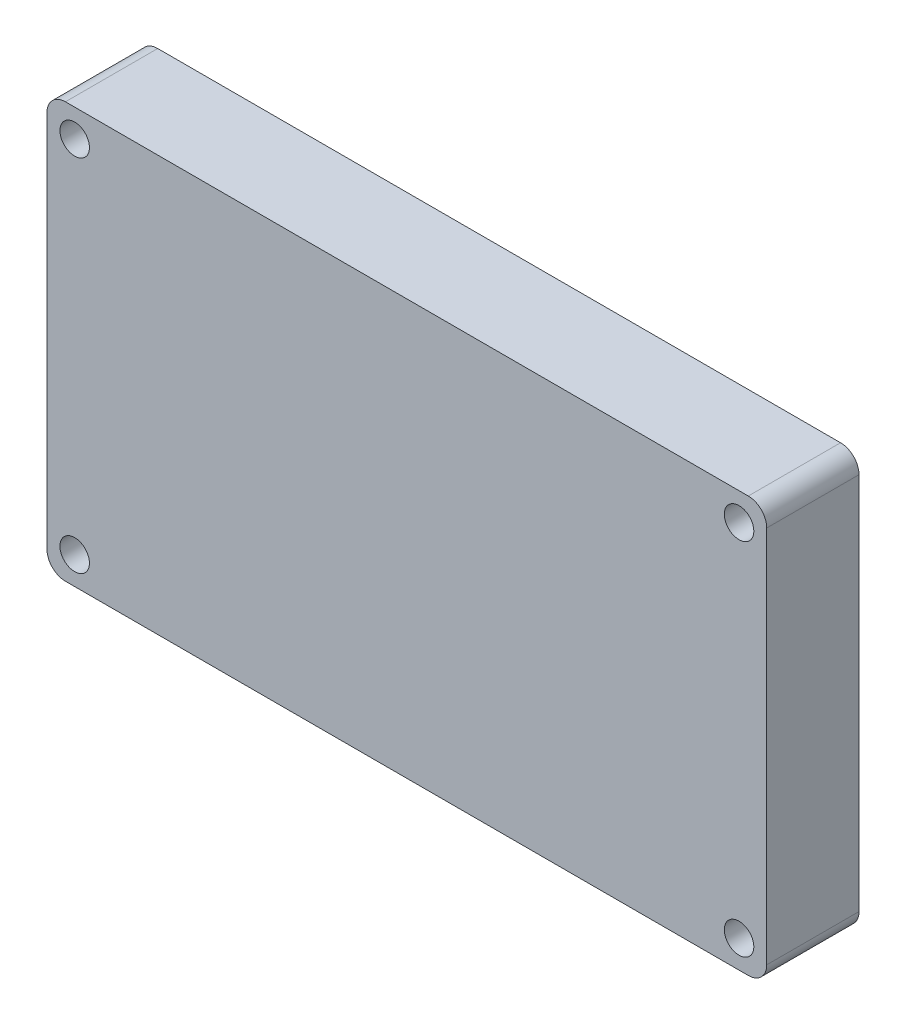
from build123d import *

# Parameters (mm, degrees)
SKETCH1_R           = 1.6
BOSS_EXTRUDE2_DEPTH = 10


with BuildPart() as part:
    # Sketch1 → Boss-Extrude2 (new body)
    with BuildSketch(Plane.XY):
        with BuildLine():
            Line((-78, 42), (-78, 43))
            ThreePointArc((-78, 43), (-77.414213562, 44.414213562), (-76, 45))
            Line((-76, 45), (-75, 45))
            Line((-75, 45), (-3, 45))
            Line((-3, 45), (-2, 45))
            ThreePointArc((-2, 45), (-0.585786438, 44.414213562), (0, 43))
            Line((0, 43), (0, 42))
            Line((0, 42), (0, 3))
            Line((0, 3), (0, 2))
            ThreePointArc((0, 2), (-0.585786438, 0.585786438), (-2, 0))
            Line((-2, 0), (-3, 0))
            Line((-3, 0), (-75, 0))
            Line((-75, 0), (-76, 0))
            ThreePointArc((-76, 0), (-77.414213562, 0.585786438), (-78, 2))
            Line((-78, 2), (-78, 3))
            Line((-78, 3), (-78, 42))
        make_face()
        with Locations((-75, 3)):
            Circle(SKETCH1_R, mode=Mode.SUBTRACT)
        with Locations((-3, 3)):
            Circle(SKETCH1_R, mode=Mode.SUBTRACT)
        with Locations((-3, 42)):
            Circle(SKETCH1_R, mode=Mode.SUBTRACT)
        with Locations((-75, 42)):
            Circle(SKETCH1_R, mode=Mode.SUBTRACT)
    extrude(amount=BOSS_EXTRUDE2_DEPTH)


solid = part.part
